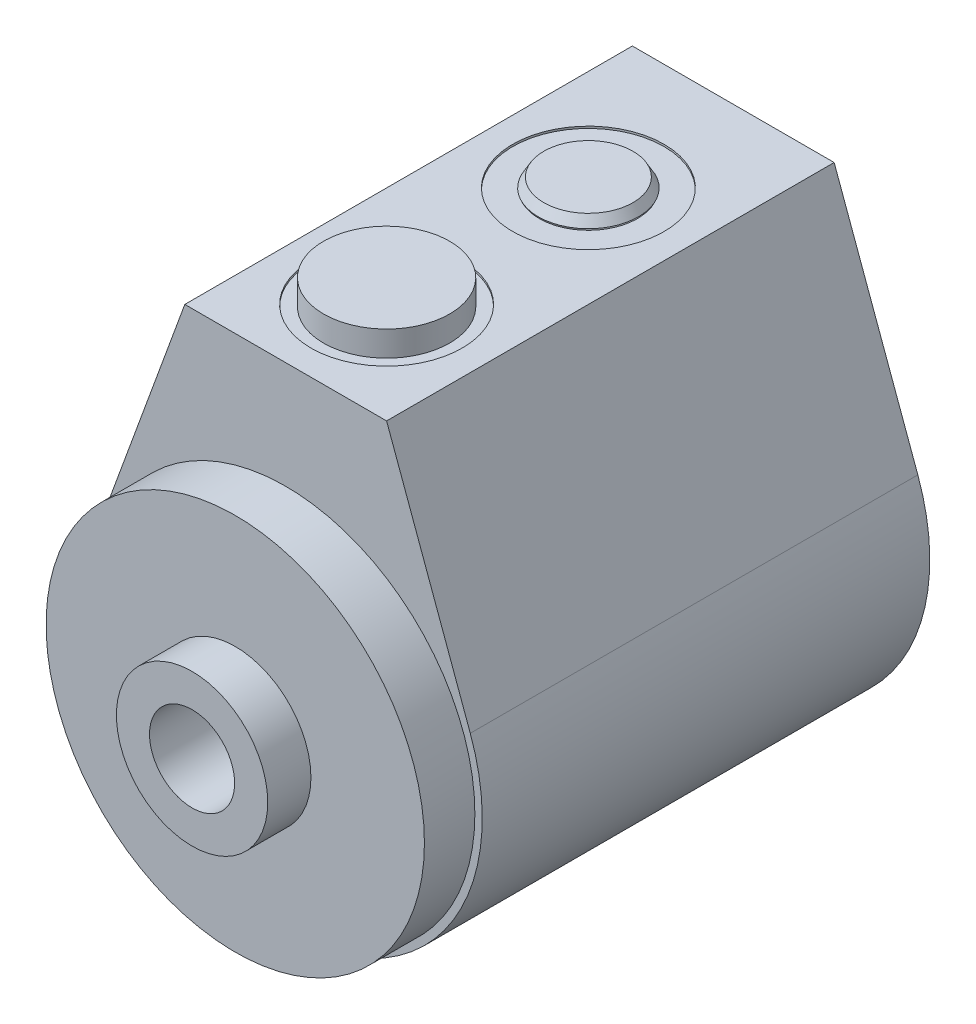
from build123d import *

# Parameters (mm, degrees)
EXTRUDE1_DEPTH     = 56.3372
HOLE1_D            = 19.05
HOLE1_DEPTH        = 0.254
HOLE2_D            = 23.876
HOLE2_DEPTH        = 6.35
SKETCH6_W          = 9.525
SKETCH6_H          = 0.9398
SKETCH8_W          = 7.9375
SKETCH8_H          = 3.175
HOLE3_D            = 6.6294
HOLE3_DEPTH        = 12.7
CIRPATTERN1_COUNT  = 2
SKETCH17_R         = 5.6007
CUT_EXTRUDE1_DEPTH = 1.3208
SKETCH18_R         = 2.5273
CUT_EXTRUDE2_DEPTH = 12.7
SKETCH19_R         = 0.889


with BuildPart() as part:
    # Sketch1 → Extrude1 (new body)
    with BuildSketch(Plane.XY.offset(56.3372)):
        with BuildLine():
            Line((23.233094839, 8.501241812), (12.7, 37.2872))
            Line((12.7, 37.2872), (-12.7, 37.2872))
            Line((-12.7, 37.2872), (-23.233094839, 8.501241812))
            ThreePointArc((-23.233094839, 8.501241812), (0, -24.7396), (23.233094839, 8.501241812))
        make_face()
    extrude(amount=-EXTRUDE1_DEPTH)

    # Hole1
    with Locations(Plane(origin=(0, 37.2872, 0), x_dir=(-1, 0, 0), z_dir=(0, 1, 0))):
        with Locations((0, 43.6372)):
            Hole(HOLE1_D / 2, depth=HOLE1_DEPTH)

    # Hole2
    with Locations(Plane(origin=(0, 0, 0), x_dir=(-1, 0, 0), z_dir=(0, 0, -1))):
        with Locations((0, 0)):
            Hole(HOLE2_D / 2, depth=HOLE2_DEPTH)

    # Sketch7 → Revolve2 (revolve)
    with BuildSketch(Plane.XZ):
        Polygon((9.525, 68.1228), (0, 68.1228), (0, 56.3372), (23.8125, 56.3372), (23.8125, 62.6872), (9.525, 62.6872), align=None)
    revolve(axis=Axis((0, 0, 0), (0, 0, 1)))

    # Sketch6 → Revolve1 (revolve)
    with BuildSketch(Plane.XZ):
        with Locations((4.7625, 5.8801)):
            Rectangle(SKETCH6_W, SKETCH6_H)
    revolve(axis=Axis((0, 0, 0), (0, 0, 1)))

    # Sketch8 → Revolve3 (revolve)
    with BuildSketch(Plane(origin=(0, 0, 32.639), x_dir=(0, 0, -1), z_dir=(1, 0, 0))):
        with Locations((-14.96695, 38.6207)):
            Rectangle(SKETCH8_W, SKETCH8_H)
    revolve(axis=Axis((0, 0, 43.6372), (0, 1, 0)))

    # Sketch9 → Cut-Revolve1 (revolve, cut)
    with BuildSketch(Plane.XY.offset(18.2372), mode=Mode.PRIVATE) as cut_revolve1_sk:
        Polygon((-4.9784, 16.4592), (0, 16.4592), (0, 37.2872), (-9.525, 37.2872), (-9.525, 37.0332), (-6.1849, 37.0332), (-5.642306865, 34.4805), (-4.9784, 33.816593135), align=None)
    revolve(cut_revolve1_sk.sketch.rotate(Axis((0, 37.2872, 18.2372), (0, -1, 0)), 90), axis=Axis((0, 37.2872, 18.2372), (0, -1, 0)), mode=Mode.SUBTRACT)  # turned: the seam where the file's is

    # Sketch10 → Cut-Revolve2 (revolve, cut)
    with BuildSketch(Plane.XY.offset(43.6372), mode=Mode.PRIVATE) as cut_revolve2_sk:
        Polygon((6.1849, 37.0332), (0, 37.0332), (0, 23.5712), (4.9784, 23.5712), (4.9784, 33.816593135), (5.642306865, 34.4805), align=None)
    revolve(cut_revolve2_sk.sketch.rotate(Axis((0, 0, 43.6372), (0, 1, 0)), 270), axis=Axis((0, 0, 43.6372), (0, 1, 0)), mode=Mode.SUBTRACT)  # turned: the seam where the file's is

    # Hole3
    with Locations(Plane(origin=(0, 0, 0), x_dir=(-1, 0, 0), z_dir=(0, 0, -1))):
        with Locations((-18.2626, 0)):
            hole3 = Hole(HOLE3_D / 2, depth=HOLE3_DEPTH)

    # CirPattern1: Hole3 ×2 about axis
    cirpattern1_axis = Axis((0, 0, 0), (0, 0, 1))
    for i in range(1, CIRPATTERN1_COUNT):
        add(hole3.rotate(cirpattern1_axis, i * 360 / CIRPATTERN1_COUNT), mode=Mode.SUBTRACT)

    # Sketch15 → Hole5 (revolve, cut)
    with BuildSketch(Plane(origin=(0, 0, 5.4102), x_dir=(0, 1, 0), z_dir=(1, 0, 0))):
        Polygon((0, 0), (0, 62.7126), (5.3594, 62.7126), (5.3594, 48.583771355), (6.7437, 47.752), (6.7437, 0), align=None)
    revolve(axis=Axis((0, 0, -0.719823899), (0, 0, 1)), mode=Mode.SUBTRACT)

    # Sketch17 → Cut-Extrude1 (cut)
    with BuildSketch(Plane(origin=(0, 0, 0), x_dir=(-1, 0, 0), z_dir=(0, 0, -1))):
        with Locations((0, 22.225)):
            Circle(SKETCH17_R)
    extrude(amount=-CUT_EXTRUDE1_DEPTH, mode=Mode.SUBTRACT)

    # Sketch18 → Cut-Extrude2 (cut)
    with BuildSketch(Plane(origin=(0, 0, 1.3208), x_dir=(-1, 0, 0), z_dir=(0, 0, -1))):
        with Locations((0, 22.225)):
            Circle(SKETCH18_R)
    extrude(amount=-CUT_EXTRUDE2_DEPTH, mode=Mode.SUBTRACT)


with BuildPart() as body_2:
    # Sketch19 → Revolve4 (revolve)
    with BuildSketch(Plane(origin=(0, 0, 0), x_dir=(0, 0, -1), z_dir=(1, 0, 0)), mode=Mode.PRIVATE) as revolve4_sk:
        with Locations((-0.4318, 26.9367)):
            Circle(SKETCH19_R)
    revolve(revolve4_sk.sketch.rotate(Axis((0, 22.225, 14.0208), (0, 0, -1)), 270), axis=Axis((0, 22.225, 14.0208), (0, 0, -1)))  # turned: the seam where the file's is


with BuildPart() as body_3:
    # Sketch20 → Revolve5 (revolve)
    with BuildSketch(Plane(origin=(0, 0, 0), x_dir=(0, 0, -1), z_dir=(1, 0, 0))):
        Polygon((-18.2372, 38.481), (-12.627240751, 38.481), (-11.938, 37.2872), (-18.2372, 37.2872), align=None)
    revolve(axis=Axis((0, 41.05444959, 18.2372), (0, -1, 0)))


solid = Compound([part.part, body_2.part, body_3.part])
